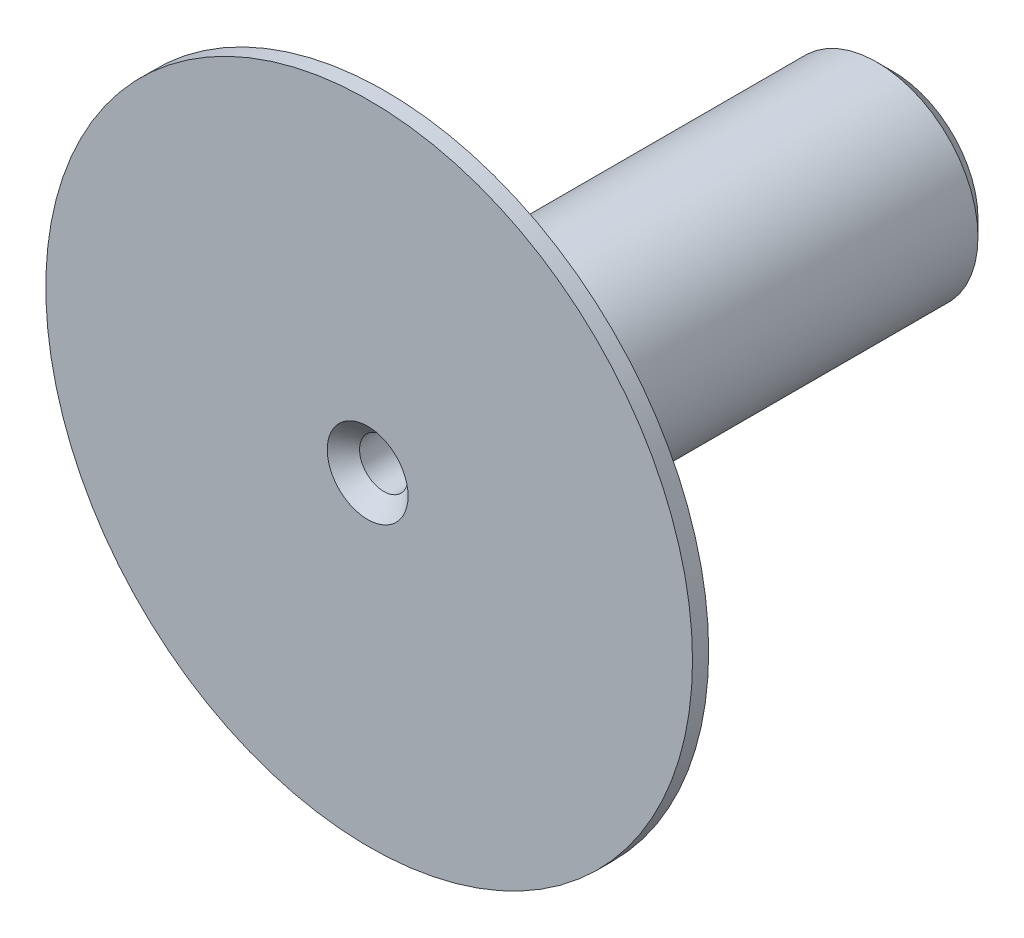
from build123d import *

# Parameters (mm, degrees)
SKETCH1_R           = 1.25
SKETCH1_R_2         = 0.3
BOSS_EXTRUDE1_DEPTH = 6.5
SKETCH2_R           = 4
SKETCH2_R_2         = 1.25
BOSS_EXTRUDE2_DEPTH = 0.2
CHAMFER1_SIZE       = 0.2


with BuildPart() as part:
    # Sketch1 → Boss-Extrude1 (new body)
    with BuildSketch(Plane.XY):
        Circle(SKETCH1_R)
        Circle(SKETCH1_R_2, mode=Mode.SUBTRACT)
    extrude(amount=BOSS_EXTRUDE1_DEPTH)

    # Sketch2 → Boss-Extrude2 (add)
    with BuildSketch(Plane.XY.offset(6.5)):
        with Locations((0.018669882, 0)):
            Circle(SKETCH2_R)
        Circle(SKETCH2_R_2, mode=Mode.SUBTRACT)
    extrude(amount=-BOSS_EXTRUDE2_DEPTH)

    # Chamfer1
    chamfer1_edges = [part.edges().sort_by_distance(p)[0] for p in [
        (-1.25, 0, 0),
        (-0.3, 0, 0),
        (-0.3, 0, 6.5),
    ]]
    chamfer(chamfer1_edges, length=CHAMFER1_SIZE)


solid = part.part
